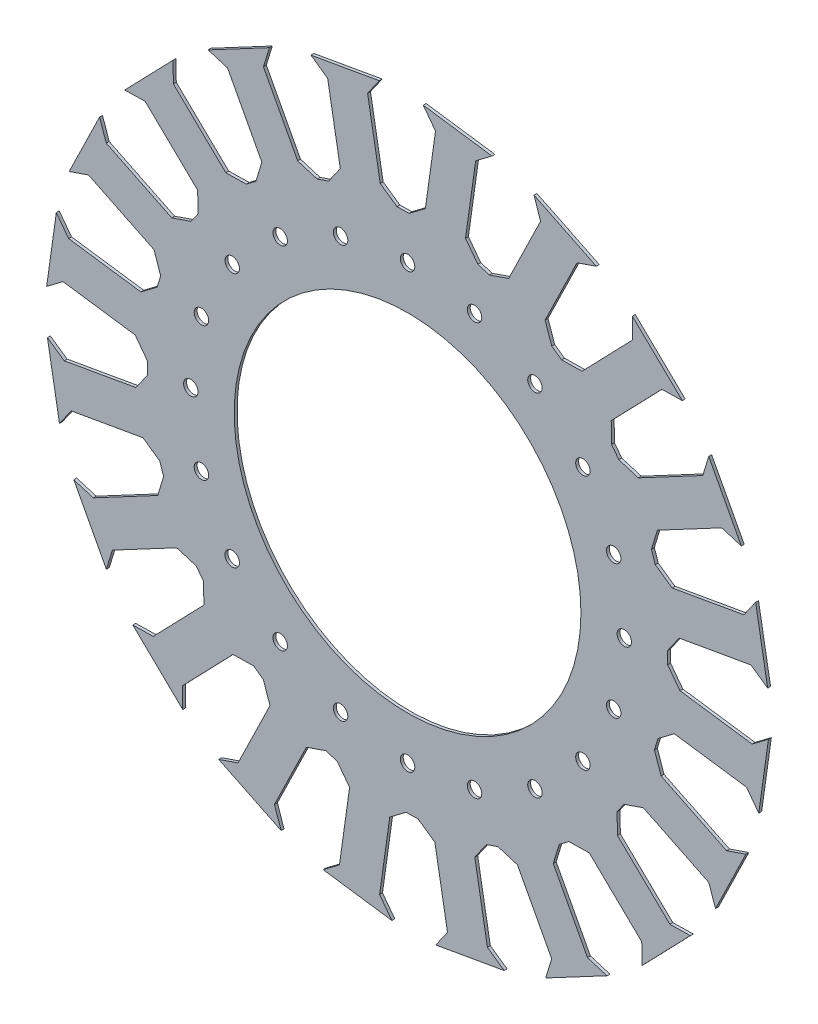
from build123d import *

# Parameters (mm, degrees)
Y_KSEKLIK_EKSTR_ZYON1_DEPTH = 1
IZIM2_R                     = 60
KES_EKSTR_ZYON1_DEPTH       = 1
IZIM3_R                     = 2.5
KES_EKSTR_ZYON2_DEPTH       = 1
IZIM5_R                     = 82.296906758
IZIM5_R_2                   = 60
Y_KSEKLIK_EKSTR_ZYON4_DEPTH = 1
IZIM6_R                     = 2.5
KES_EKSTR_ZYON3_DEPTH       = 1


with BuildPart() as part:
    # Çizim1 → Yükseklik-Ekstrüzyon1 (new body)
    with BuildSketch(Plane.XY):
        Polygon((-3.655966564, 89.925713278), (-1.570294625, 89.962118817), (0.515377314, 89.998524356), (6.162583162, 94.253999195), (9.673478824, 119.235319882), (5.418003985, 124.882525731), (29.214169481, 121.538192769), (23.566963633, 117.28271793), (20.056067971, 92.301397243), (24.31154281, 86.654191394), (26.306384629, 86.044307046), (28.301226447, 85.434422697), (34.987052413, 87.736537195), (46.045765244, 110.410258595), (43.743650746, 117.096084561), (65.341693285, 106.562015365), (58.655867319, 104.259900868), (47.597154488, 81.586179467), (49.899268986, 74.900353502), (51.608011668, 73.703878995), (53.31675435, 72.507404488), (60.386745204, 72.630811638), (77.910771342, 90.777471923), (77.787364193, 97.847462777), (95.073116887, 81.154805437), (88.003126033, 81.031398287), (70.479099894, 62.884738001), (70.602507044, 55.814747147), (71.85788695, 54.148801743), (73.113266857, 52.482856339), (79.875362635, 50.415476189), (102.149328305, 62.258753816), (104.216708455, 69.020849594), (115.498121395, 47.803597713), (108.736025616, 49.870977863), (86.462059946, 38.027700236), (84.394679796, 31.265604458), (85.073811595, 29.2932625), (85.752943394, 27.320920542), (91.545223047, 23.265122665), (116.388797298, 27.645715103), (120.444595174, 33.437994756), (124.617365058, 9.773040778), (118.825085404, 13.828838655), (93.981511154, 9.448246217), (89.925713278, 3.655966564), (89.962118817, 1.570294625), (89.998524356, -0.515377314), (94.253999195, -6.162583162), (119.235319882, -9.673478823), (124.882525731, -5.418003985), (121.538192769, -29.214169481), (117.28271793, -23.566963633), (92.301397243, -20.056067971), (86.654191394, -24.31154281), (86.044307046, -26.306384629), (85.434422697, -28.301226447), (87.736537195, -34.987052413), (110.410258595, -46.045765244), (117.096084561, -43.743650746), (106.562015365, -65.341693284), (104.259900868, -58.655867319), (81.586179467, -47.597154488), (74.900353502, -49.899268986), (73.703878995, -51.608011668), (72.507404488, -53.31675435), (72.630811638, -60.386745204), (90.777471923, -77.910771342), (97.847462777, -77.787364193), (81.154805437, -95.073116887), (81.031398287, -88.003126033), (62.884738001, -70.479099894), (55.814747147, -70.602507044), (54.148801743, -71.85788695), (52.482856339, -73.113266857), (50.415476189, -79.875362635), (62.258753816, -102.149328305), (69.020849594, -104.216708455), (47.803597713, -115.498121395), (49.870977863, -108.736025616), (38.027700236, -86.462059946), (31.265604458, -84.394679796), (29.2932625, -85.073811595), (27.320920542, -85.752943394), (23.265122665, -91.545223047), (27.645715103, -116.388797297), (33.437994756, -120.444595174), (9.773040778, -124.617365058), (13.828838655, -118.825085404), (9.448246217, -93.981511154), (3.655966564, -89.925713278), (1.570294625, -89.962118817), (-0.515377314, -89.998524356), (-6.162583162, -94.253999195), (-9.673478823, -119.235319882), (-5.418003985, -124.88252573), (-29.214169481, -121.538192769), (-23.566963633, -117.28271793), (-20.056067971, -92.301397243), (-24.31154281, -86.654191394), (-26.306384629, -86.044307046), (-28.301226447, -85.434422697), (-34.987052413, -87.736537195), (-46.045765244, -110.410258595), (-43.743650746, -117.096084561), (-65.341693284, -106.562015365), (-58.655867319, -104.259900868), (-47.597154488, -81.586179467), (-49.899268986, -74.900353502), (-51.608011668, -73.703878995), (-53.31675435, -72.507404488), (-60.386745204, -72.630811638), (-77.910771342, -90.777471923), (-77.787364193, -97.847462777), (-95.073116887, -81.154805437), (-88.003126033, -81.031398287), (-70.479099894, -62.884738001), (-70.602507044, -55.814747147), (-71.85788695, -54.148801743), (-73.113266857, -52.482856339), (-79.875362635, -50.415476189), (-102.149328305, -62.258753816), (-104.216708455, -69.020849594), (-115.498121395, -47.803597713), (-108.736025616, -49.870977863), (-86.462059946, -38.027700236), (-84.394679796, -31.265604458), (-85.073811595, -29.2932625), (-85.752943394, -27.320920542), (-91.545223047, -23.265122665), (-116.388797297, -27.645715103), (-120.444595174, -33.437994756), (-124.617365058, -9.773040778), (-118.825085404, -13.828838655), (-93.981511154, -9.448246217), (-89.925713278, -3.655966564), (-89.962118817, -1.570294625), (-89.998524356, 0.515377314), (-94.253999195, 6.162583162), (-119.235319882, 9.673478824), (-124.88252573, 5.418003985), (-121.538192769, 29.214169481), (-117.28271793, 23.566963633), (-92.301397243, 20.056067971), (-86.654191394, 24.31154281), (-86.044307046, 26.306384629), (-85.434422697, 28.301226447), (-87.736537195, 34.987052413), (-110.410258595, 46.045765244), (-117.096084561, 43.743650746), (-106.562015365, 65.341693284), (-104.259900868, 58.655867319), (-81.586179467, 47.597154488), (-74.900353502, 49.899268986), (-73.703878995, 51.608011668), (-72.507404488, 53.31675435), (-72.630811638, 60.386745204), (-90.777471923, 77.910771342), (-97.847462777, 77.787364193), (-81.154805437, 95.073116887), (-81.031398287, 88.003126033), (-62.884738001, 70.479099894), (-55.814747147, 70.602507044), (-54.148801743, 71.85788695), (-52.482856339, 73.113266857), (-50.415476189, 79.875362635), (-62.258753816, 102.149328305), (-69.020849594, 104.216708455), (-47.803597713, 115.498121395), (-49.870977863, 108.736025616), (-38.027700236, 86.462059946), (-31.265604458, 84.394679796), (-29.2932625, 85.073811595), (-27.320920542, 85.752943394), (-23.265122665, 91.545223047), (-27.645715103, 116.388797298), (-33.437994756, 120.444595174), (-9.773040778, 124.617365058), (-13.828838655, 118.825085404), (-9.448246217, 93.981511154), align=None)
    extrude(amount=Y_KSEKLIK_EKSTR_ZYON1_DEPTH)

    # Çizim2 → Kes-Ekstrüzyon1 (cut)
    with BuildSketch(Plane.XY.offset(1)):
        Circle(IZIM2_R)
    extrude(amount=-KES_EKSTR_ZYON1_DEPTH, mode=Mode.SUBTRACT)

    # Çizim3 → Kes-Ekstrüzyon2 (cut)
    with BuildSketch(Plane.XY.offset(1)):
        with Locations((37.5, 64.951905284)):
            Circle(IZIM3_R)
        with Locations((0, 75)):
            Circle(IZIM3_R)
        with Locations((64.951905284, 37.5)):
            Circle(IZIM3_R)
        with Locations((75, 0)):
            Circle(IZIM3_R)
        with Locations((64.951905284, -37.5)):
            Circle(IZIM3_R)
        with Locations((37.5, -64.951905284)):
            Circle(IZIM3_R)
        with Locations((0, -75)):
            Circle(IZIM3_R)
        with Locations((-37.5, -64.951905284)):
            Circle(IZIM3_R)
        with Locations((-64.951905284, -37.5)):
            Circle(IZIM3_R)
        with Locations((-75, 0)):
            Circle(IZIM3_R)
        with Locations((-64.951905284, 37.5)):
            Circle(IZIM3_R)
        with Locations((-37.5, 64.951905284)):
            Circle(IZIM3_R)
    extrude(amount=-KES_EKSTR_ZYON2_DEPTH, mode=Mode.SUBTRACT)

    # Çizim5 → Yükseklik-Ekstrüzyon4 (add)
    with BuildSketch(Plane.XY.offset(1)):
        Circle(IZIM5_R)
        Circle(IZIM5_R_2, mode=Mode.SUBTRACT)
    extrude(amount=-Y_KSEKLIK_EKSTR_ZYON4_DEPTH)

    # Çizim6 → Kes-Ekstrüzyon3 (cut)
    with BuildSketch(Plane.XY.offset(1)):
        with Locations((23.176274578, 71.329238722)):
            Circle(IZIM6_R)
        with Locations((0, 75)):
            Circle(IZIM6_R)
        with Locations((44.083893922, 60.676274578)):
            Circle(IZIM6_R)
        with Locations((60.676274578, 44.083893922)):
            Circle(IZIM6_R)
        with Locations((71.329238722, 23.176274578)):
            Circle(IZIM6_R)
        with Locations((75, 0)):
            Circle(IZIM6_R)
        with Locations((71.329238722, -23.176274578)):
            Circle(IZIM6_R)
        with Locations((60.676274578, -44.083893922)):
            Circle(IZIM6_R)
        with Locations((44.083893922, -60.676274578)):
            Circle(IZIM6_R)
        with Locations((23.176274578, -71.329238722)):
            Circle(IZIM6_R)
        with Locations((0, -75)):
            Circle(IZIM6_R)
        with Locations((-23.176274578, -71.329238722)):
            Circle(IZIM6_R)
        with Locations((-44.083893922, -60.676274578)):
            Circle(IZIM6_R)
        with Locations((-60.676274578, -44.083893922)):
            Circle(IZIM6_R)
        with Locations((-71.329238722, -23.176274578)):
            Circle(IZIM6_R)
        with Locations((-75, 0)):
            Circle(IZIM6_R)
        with Locations((-71.329238722, 23.176274578)):
            Circle(IZIM6_R)
        with Locations((-60.676274578, 44.083893922)):
            Circle(IZIM6_R)
        with Locations((-44.083893922, 60.676274578)):
            Circle(IZIM6_R)
        with Locations((-23.176274578, 71.329238722)):
            Circle(IZIM6_R)
    extrude(amount=-KES_EKSTR_ZYON3_DEPTH, mode=Mode.SUBTRACT)


solid = part.part
